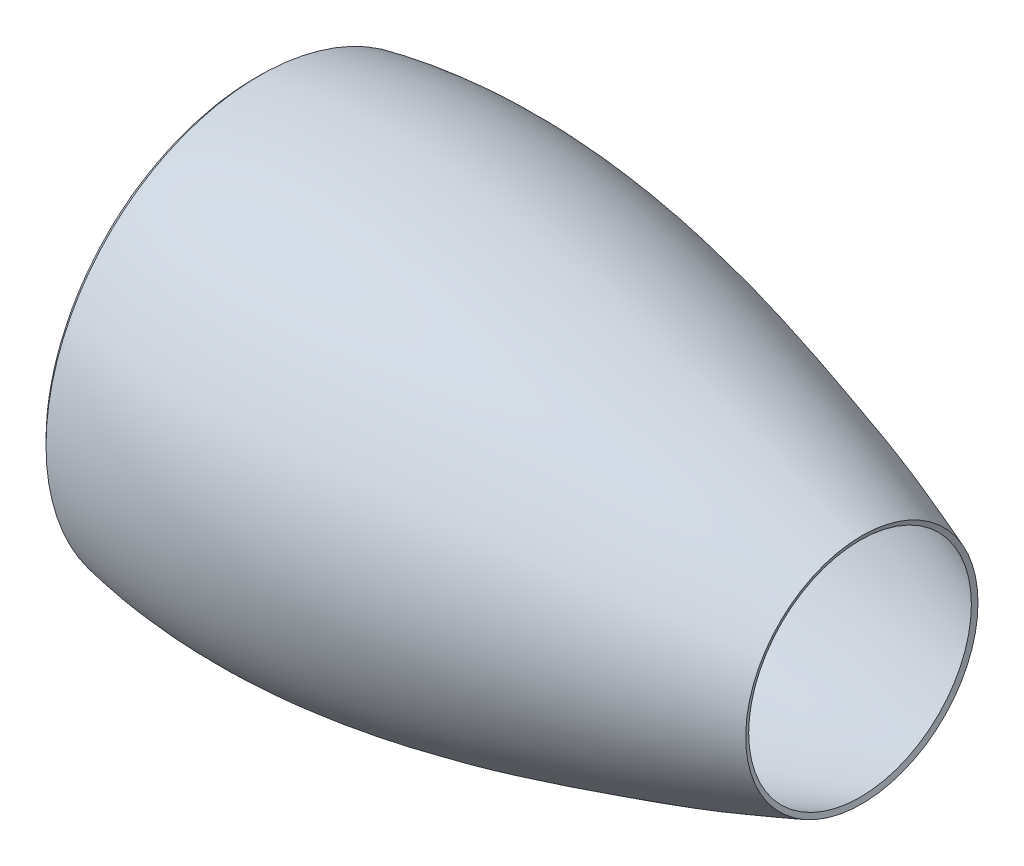
from build123d import *

# Parameters (mm, degrees)
THICKEN1_T1 = 5


with BuildPart() as body_1:
    # Surface-Revolve1: a surface, the sketch's curves turned about an axis
    with BuildLine(Plane.XY, mode=Mode.PRIVATE) as surface_revolve1_1_path:
        Line((65.425683209, 190), (40.425683209, 190))
        Line((40.425683209, 190), (25, 180))
        Line((25, 180), (0, 180))
        add(Edge.make_bspline(
            [(0, 180), (-12.761545779, 191.122989411), (0, 202.630876458)],
            knots=[0, 0, 0, 1, 1, 1], degree=2))
        add(Edge.make_bspline(
            [(0, 202.630876458), (162.717006582, 235.034574592), (447.29951891, 152.468770908), (506.646826016, 135.603621005), (580, 108)],
            knots=[0, 0, 0, 0, 0.626334712, 1, 1, 1, 1], degree=3))
    surface_revolve1_1 = Shell.revolve(surface_revolve1_1_path.wire(), 360, Axis((0, 0, 0), (1, 0, 0)))
    add(Solid.thicken(surface_revolve1_1, THICKEN1_T1))


solid = body_1.part
